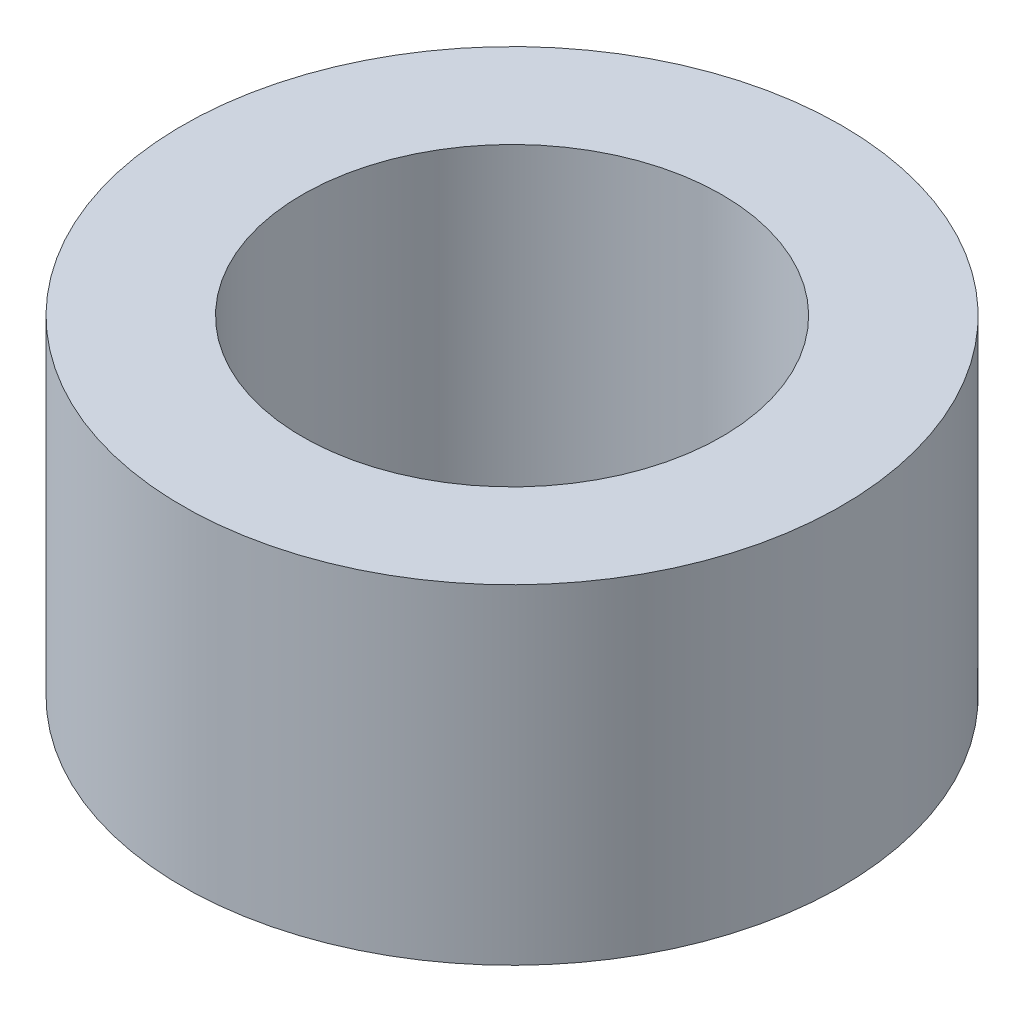
from build123d import *

# Parameters (mm, degrees)
ESQUISSE1_W = 2
ESQUISSE1_H = 5.5


with BuildPart() as part:
    # Esquisse1 → Révolution1 (revolve)
    with BuildSketch(Plane.XY):
        with Locations((4.5, 2.75)):
            Rectangle(ESQUISSE1_W, ESQUISSE1_H)
    revolve(axis=Axis((0, 0, 0), (0, 1, 0)))


solid = part.part
